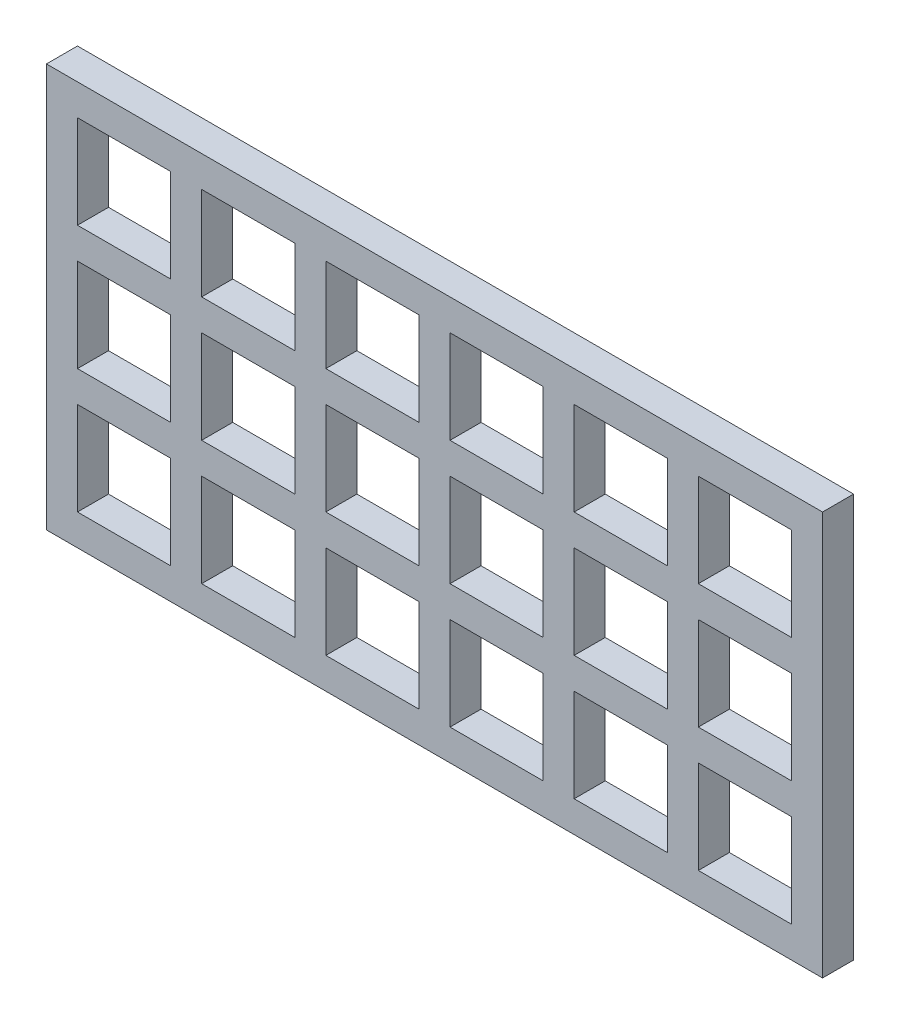
from build123d import *

# Parameters (mm, degrees)
SKETCH_1_W                  = 125
SKETCH_1_H                  = 65
EXTRUDE_1_DEPTH             = 5
SKETCH_2_W                  = 15
SKETCH_2_H                  = 15
CUT_EXTRUDE_1_DEPTH         = 5
PATTERN_LINEAR_1_COUNT      = 6
PATTERN_LINEAR_1_PITCH      = 20
PATTERN_LINEAR_1_COUNT_DIR2 = 3
PATTERN_LINEAR_1_PITCH_DIR2 = 20


with BuildPart() as part:
    # 草图1 → 凸台-拉伸1 (new body)
    with BuildSketch(Plane.XY):
        Rectangle(SKETCH_1_W, SKETCH_1_H)
    extrude(amount=EXTRUDE_1_DEPTH)

    # 草图2 → 切除-拉伸1 (cut)
    with BuildSketch(Plane.XY.offset(5)):
        with Locations((-50, 20)):
            Rectangle(SKETCH_2_W, SKETCH_2_H)
    cut_extrude_1 = extrude(amount=-CUT_EXTRUDE_1_DEPTH, mode=Mode.SUBTRACT)

    # 阵列(线性)1: Cut-Extrude 1 6 × 3
    with Locations(*[(i * PATTERN_LINEAR_1_PITCH, -j * PATTERN_LINEAR_1_PITCH_DIR2, 0) for i in range(PATTERN_LINEAR_1_COUNT) for j in range(PATTERN_LINEAR_1_COUNT_DIR2) if (i, j) != (0, 0)]):
        add(cut_extrude_1, mode=Mode.SUBTRACT)


solid = part.part
